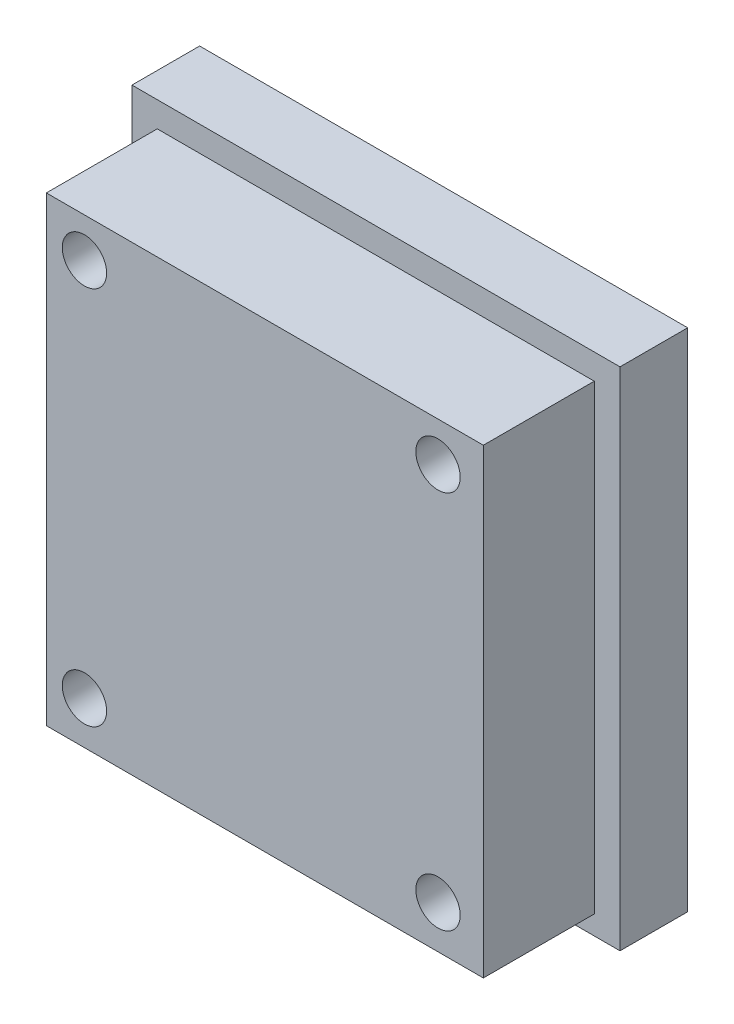
from build123d import *

# Parameters (mm, degrees)
SKETCH1_W           = 39.4
SKETCH1_H           = 41.6
BOSS_EXTRUDE1_DEPTH = 16.1
SKETCH1_3_W         = 44
SKETCH1_3_H         = 45.6
SKETCH1_3_W_2       = 39.4
SKETCH1_3_H_2       = 41.6
BOSS_EXTRUDE2_DEPTH = 6.1
SKETCH2_R           = 2
CUT_EXTRUDE1_DEPTH  = 39.919090431


with BuildPart() as part:
    # Sketch1 → Boss-Extrude1 (new body)
    with BuildSketch(Plane.XY):
        with Locations((-4.36, -1.18)):
            Rectangle(SKETCH1_W, SKETCH1_H)
    extrude(amount=BOSS_EXTRUDE1_DEPTH)

    # Sketch1_3 → Boss-Extrude2 (add)
    with BuildSketch(Plane.XY):
        with Locations((-4.34, -0.9)):
            Rectangle(SKETCH1_3_W, SKETCH1_3_H)
        with Locations((-4.36, -1.18)):
            Rectangle(SKETCH1_3_W_2, SKETCH1_3_H_2, mode=Mode.SUBTRACT)
    extrude(amount=BOSS_EXTRUDE2_DEPTH)

    # Sketch2 → Cut-Extrude1 (cut, through all)
    with BuildSketch(Plane.XY.offset(16.1)):
        with Locations((-20.623955183, -18.125224269)):
            Circle(SKETCH2_R)
        with Locations((-20.623955183, 16.074219179)):
            Circle(SKETCH2_R)
        with Locations((11.253691187, 16.074219179)):
            Circle(SKETCH2_R)
        with Locations((11.253691187, -18.125224269)):
            Circle(SKETCH2_R)
    extrude(amount=-CUT_EXTRUDE1_DEPTH, mode=Mode.SUBTRACT)


solid = part.part
